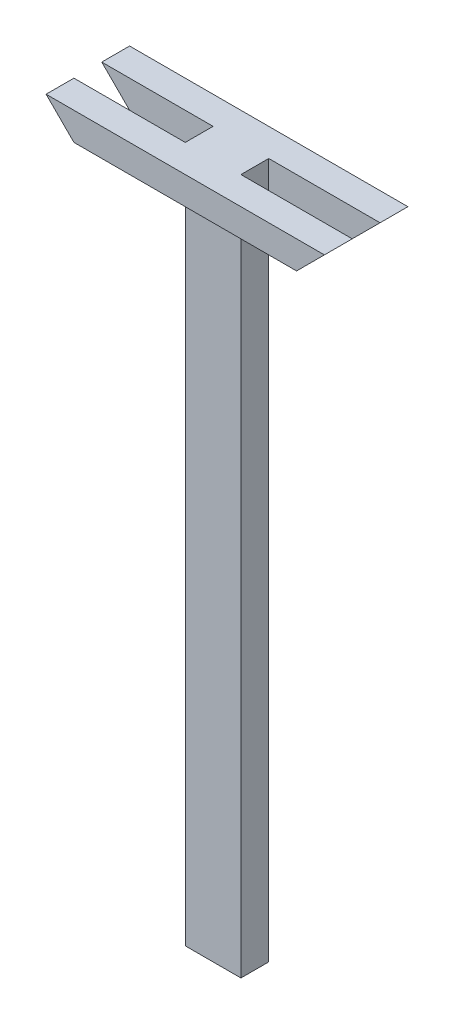
from build123d import *

# Parameters (mm, degrees)
SKETCH_1_W          = 80
SKETCH_1_H          = 40
EXTRUDE_1_DEPTH     = 1000
SKETCH_2_W          = 400
SKETCH_2_H          = 40
EXTRUDE_2_DEPTH     = 40
SKETCH_3_W          = 400
SKETCH_3_H          = 40
EXTRUDE_3_DEPTH     = 40
CUT_EXTRUDE_1_DEPTH = 121


with BuildPart() as part:
    # 草图1 → 凸台-拉伸1 (new body)
    with BuildSketch(Plane(origin=(0, 0, 0), x_dir=(1, 0, 0), z_dir=(0, 1, 0))):
        with Locations((40, -20)):
            Rectangle(SKETCH_1_W, SKETCH_1_H)
    extrude(amount=EXTRUDE_1_DEPTH)

    # 草图2 → 凸台-拉伸2 (add)
    with BuildSketch(Plane.XY.offset(40)):
        with Locations((40, 980)):
            Rectangle(SKETCH_2_W, SKETCH_2_H)
    extrude(amount=EXTRUDE_2_DEPTH)

    # 草图3 → 凸台-拉伸3 (add)
    with BuildSketch(Plane(origin=(0, 0, 0), x_dir=(-1, 0, 0), z_dir=(0, 0, -1))):
        with Locations((-40, 980)):
            Rectangle(SKETCH_3_W, SKETCH_3_H)
    extrude(amount=EXTRUDE_3_DEPTH)

    # 草图4 → 切除-拉伸1 (cut, through all)
    with BuildSketch(Plane.XY.offset(80)):
        Polygon((-160, 1000), (-120, 960), (-160, 960), align=None)
        Polygon((240, 1000), (200, 960), (240, 960), align=None)
    extrude(amount=-CUT_EXTRUDE_1_DEPTH, mode=Mode.SUBTRACT)


solid = part.part
